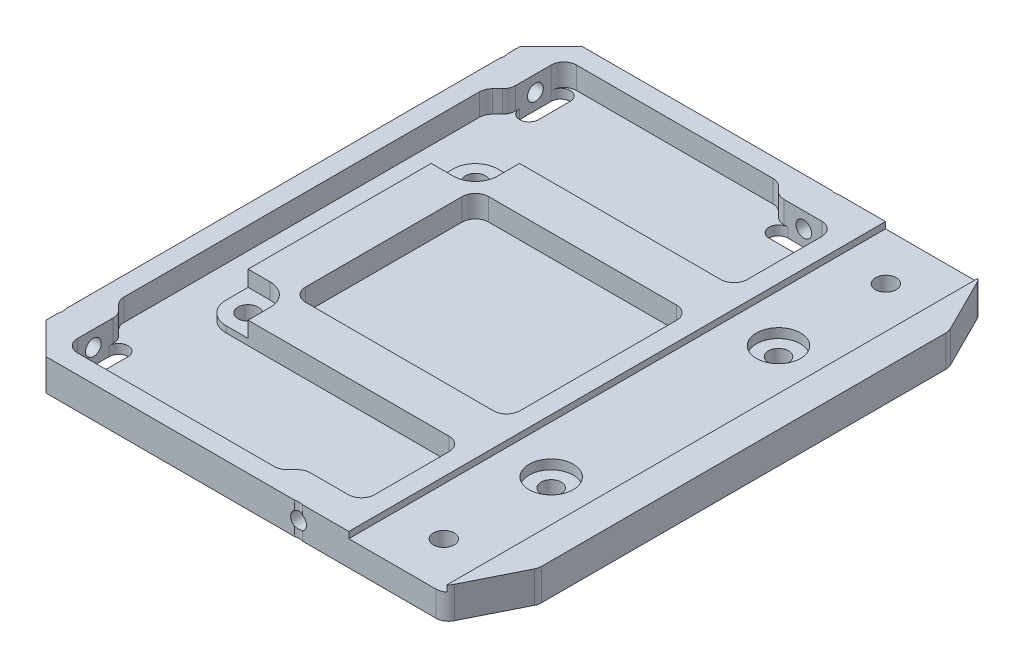
from build123d import *

# Parameters (mm, degrees)
SKETCH_1_R          = 1.6
SKETCH_1_R_2        = 1.65
EXTRUDE_1_DEPTH     = 5
FILLET_1_R          = 2
SKETCH_2_R          = 3.5
CUT_EXTRUDE_1_DEPTH = 2.5
SKETCH_3_W          = 15.1
SKETCH_3_H          = 85
CUT_EXTRUDE_2_DEPTH = 1
SKETCH_4_R          = 1.25
CUT_EXTRUDE_3_DEPTH = 5
CHAMFER_1_SIZE      = 5
SKETCH_6_R          = 1.25
CUT_EXTRUDE_5_DEPTH = 5
SKETCH_7_R          = 1.25
CUT_EXTRUDE_6_DEPTH = 5
SKETCH_5_R          = 2.1
CUT_EXTRUDE_4_DEPTH = 6
CUT_EXTRUDE_7_DEPTH = 2.5
CUT_EXTRUDE_9_DEPTH = 6.0000001
SKETCH_9_W          = 33.95
SKETCH_9_H          = 29
CUT_EXTRUDE_8_DEPTH = 3.5
FILLET_29_R         = 2.1
FILLET_30_R         = 2


with BuildPart() as part:
    # ｽｹｯﾁ1 → ﾎﾞｽ - 押し出し1 (new body)
    with BuildSketch(Plane(origin=(0, 0, 0), x_dir=(1, 0, 0), z_dir=(0, 1, 0))):
        Polygon((-36.5, -42.5), (31.5, -42.5), (36.5, -32.5), (36.5, 32.5), (31.5, 42.5), (-36.5, 42.5), align=None)
        with Locations((-24, -18)):
            Circle(SKETCH_1_R, mode=Mode.SUBTRACT)
        with Locations((-24, 18)):
            Circle(SKETCH_1_R, mode=Mode.SUBTRACT)
        with Locations((24, 35)):
            Circle(SKETCH_1_R_2, mode=Mode.SUBTRACT)
        with Locations((24, -35)):
            Circle(SKETCH_1_R_2, mode=Mode.SUBTRACT)
        with Locations((24, -18)):
            Circle(SKETCH_1_R, mode=Mode.SUBTRACT)
        with Locations((24, 18)):
            Circle(SKETCH_1_R, mode=Mode.SUBTRACT)
    extrude(amount=EXTRUDE_1_DEPTH)

    # ﾌｨﾚｯﾄ1
    fillet_1_edges = [part.edges().sort_by_distance(p)[0] for p in [
        (31.5, 2.5, -42.5),
        (36.5, 2.5, -32.5),
        (36.5, 2.5, 32.5),
        (31.5, 2.5, 42.5),
    ]]
    fillet(fillet_1_edges, radius=FILLET_1_R)

    # ｽｹｯﾁ2 → ｶｯﾄ - 押し出し1 (cut)
    with BuildSketch(Plane(origin=(0, 5, 0), x_dir=(1, 0, 0), z_dir=(0, 1, 0))):
        with Locations((24, 18)):
            Circle(SKETCH_2_R)
        with Locations((24, -18)):
            Circle(SKETCH_2_R)
    extrude(amount=-CUT_EXTRUDE_1_DEPTH, mode=Mode.SUBTRACT)

    # ｽｹｯﾁ3 → ｶｯﾄ - 押し出し2 (cut)
    with BuildSketch(Plane(origin=(0, 5, 0), x_dir=(1, 0, 0), z_dir=(0, 1, 0))):
        with Locations((24, 0)):
            Rectangle(SKETCH_3_W, SKETCH_3_H)
    extrude(amount=-CUT_EXTRUDE_2_DEPTH, mode=Mode.SUBTRACT)

    # ｽｹｯﾁ4 → ｶｯﾄ - 押し出し3 (cut)
    with BuildSketch(Plane.ZY.offset(36.5)):
        with Locations((-35, 2.5)):
            Circle(SKETCH_4_R)
        with Locations((35, 2.5)):
            Circle(SKETCH_4_R)
    extrude(amount=-CUT_EXTRUDE_3_DEPTH, mode=Mode.SUBTRACT)

    # 面取り1
    chamfer_1_edges = [part.edges().sort_by_distance(p)[0] for p in [
        (-36.5, 2.5, 42.5),
        (-36.5, 2.5, -42.5),
    ]]
    chamfer(chamfer_1_edges, length=CHAMFER_1_SIZE)

    # ｽｹｯﾁ6 → ｶｯﾄ - 押し出し5 (cut)
    with BuildSketch(Plane.XY.offset(42.5)):
        with Locations((8.5, 2.5)):
            Circle(SKETCH_6_R)
    extrude(amount=-CUT_EXTRUDE_5_DEPTH, mode=Mode.SUBTRACT)

    # ｽｹｯﾁ7 → ｶｯﾄ - 押し出し6 (cut)
    with BuildSketch(Plane(origin=(0, 0, -42.5), x_dir=(-1, 0, 0), z_dir=(0, 0, -1))):
        with Locations((-8.5, 2.5)):
            Circle(SKETCH_7_R)
    extrude(amount=-CUT_EXTRUDE_6_DEPTH, mode=Mode.SUBTRACT)

    # ｽｹｯﾁ5 → ｶｯﾄ - 押し出し4 (cut, through all)
    with BuildSketch(Plane(origin=(0, 5, 0), x_dir=(1, 0, 0), z_dir=(0, 1, 0))):
        with Locations((-38.5, 35)):
            Circle(SKETCH_5_R)
        with Locations((-38.5, -35)):
            Circle(SKETCH_5_R)
        with Locations((8.5, -44.5)):
            Circle(SKETCH_5_R)
        with Locations((8.5, 44.5)):
            Circle(SKETCH_5_R)
    extrude(amount=-CUT_EXTRUDE_4_DEPTH, mode=Mode.SUBTRACT)

    # ｽｹｯﾁ8 → ｶｯﾄ - 押し出し7 (cut)
    with BuildSketch(Plane(origin=(0, 5, 0), x_dir=(1, 0, 0), z_dir=(0, 1, 0))):
        with BuildLine():
            Line((-20.5, 18), (-20.5, 21.5))
            Line((-20.5, 21.5), (-24, 21.5))
            ThreePointArc((-24, 21.5), (-26.474873734, 20.474873734), (-27.5, 18))
            Line((-27.5, 18), (-27.5, 14.5))
            Line((-27.5, 14.5), (-24, 14.5))
            ThreePointArc((-24, 14.5), (-21.525126266, 15.525126266), (-20.5, 18))
        make_face()
        with BuildLine():
            Line((-27.5, -18), (-27.5, -14.5))
            Line((-27.5, -14.5), (-24, -14.5))
            ThreePointArc((-24, -14.5), (-21.525126266, -15.525126266), (-20.5, -18))
            Line((-20.5, -18), (-20.5, -21.5))
            Line((-20.5, -21.5), (-24, -21.5))
            ThreePointArc((-24, -21.5), (-26.474873734, -20.474873734), (-27.5, -18))
        make_face()
    extrude(amount=-CUT_EXTRUDE_7_DEPTH, mode=Mode.SUBTRACT)

    # ｽｹｯﾁ10 → ｶｯﾄ - 押し出し9 (cut, through all)
    with BuildSketch(Plane(origin=(0, 5, 0), x_dir=(1, 0, 0), z_dir=(0, 1, 0))):
        with BuildLine():
            Line((-31.5, 32.5), (-31.5, 37.5))
            ThreePointArc((-31.5, 37.5), (-30, 39), (-28.5, 37.5))
            Line((-28.5, 37.5), (-28.5, 32.5))
            ThreePointArc((-28.5, 32.5), (-30, 31), (-31.5, 32.5))
        make_face()
        with BuildLine():
            Line((6, 37.5), (11, 37.5))
            ThreePointArc((11, 37.5), (12.5, 36), (11, 34.5))
            Line((11, 34.5), (6, 34.5))
            ThreePointArc((6, 34.5), (4.5, 36), (6, 37.5))
        make_face()
        with BuildLine():
            Line((6, -37.5), (11, -37.5))
            ThreePointArc((11, -37.5), (12.5, -36), (11, -34.5))
            Line((11, -34.5), (6, -34.5))
            ThreePointArc((6, -34.5), (4.5, -36), (6, -37.5))
        make_face()
        with BuildLine():
            Line((-31.5, -32.5), (-31.5, -37.5))
            ThreePointArc((-31.5, -37.5), (-30, -39), (-28.5, -37.5))
            Line((-28.5, -37.5), (-28.5, -32.5))
            ThreePointArc((-28.5, -32.5), (-30, -31), (-31.5, -32.5))
        make_face()
    extrude(amount=-CUT_EXTRUDE_9_DEPTH, mode=Mode.SUBTRACT)

    # ｽｹｯﾁ9 → ｶｯﾄ - 押し出し8 (cut)
    with BuildSketch(Plane(origin=(0, 5, 0), x_dir=(1, 0, 0), z_dir=(0, 1, 0))):
        with Locations((-3.525, 0)):
            Rectangle(SKETCH_9_W, SKETCH_9_H)
        with BuildLine():
            Line((-24, 21.5), (13.45, 21.5))
            Line((13.45, 21.5), (13.45, 34.5))
            Line((13.45, 34.5), (13.45, 37.5))
            Line((13.45, 37.5), (11, 37.5))
            Line((11, 37.5), (6, 37.5))
            Line((6, 37.5), (4.5, 37.5))
            Line((4.5, 37.5), (2.5, 39.5))
            Line((2.5, 39.5), (-31.5, 39.5))
            Line((-31.5, 39.5), (-31.5, 37.5))
            Line((-31.5, 37.5), (-31.5, 32.5))
            Line((-31.5, 32.5), (-31.5, 31))
            Line((-31.5, 31), (-33.5, 29))
            Line((-33.5, 29), (-33.5, -29))
            Line((-33.5, -29), (-31.5, -31))
            Line((-31.5, -31), (-31.5, -32.5))
            Line((-31.5, -32.5), (-31.5, -37.5))
            Line((-31.5, -37.5), (-31.5, -39.5))
            Line((-31.5, -39.5), (2.5, -39.5))
            Line((2.5, -39.5), (4.5, -37.5))
            Line((4.5, -37.5), (6, -37.5))
            Line((6, -37.5), (11, -37.5))
            Line((11, -37.5), (13.45, -37.5))
            Line((13.45, -37.5), (13.45, -34.5))
            Line((13.45, -34.5), (13.45, -21.5))
            Line((13.45, -21.5), (-24, -21.5))
            ThreePointArc((-24, -21.5), (-26.474873734, -20.474873734), (-27.5, -18))
            Line((-27.5, -18), (-27.5, 18))
            ThreePointArc((-27.5, 18), (-26.474873734, 20.474873734), (-24, 21.5))
        make_face()
    extrude(amount=-CUT_EXTRUDE_8_DEPTH, mode=Mode.SUBTRACT)

    # ﾌｨﾚｯﾄ29
    fillet_29_edges = [part.edges().sort_by_distance(p)[0] for p in [
        (13.45, 3.25, -21.5),
        (4.5, 3.25, -37.5),
        (13.45, 3.25, 37.5),
        (-31.5, 3.25, -31),
        (13.45, 3.25, 21.5),
        (4.5, 3.25, 37.5),
        (2.5, 3.25, 39.5),
        (-31.5, 3.25, 31),
        (-33.5, 3.25, 29),
        (-33.5, 3.25, -29),
        (2.5, 3.25, -39.5),
        (13.45, 3.25, -37.5),
        (-20.5, 3.25, 14.5),
        (-20.5, 3.25, -14.5),
        (13.45, 3.25, -14.5),
        (13.45, 3.25, 14.5),
    ]]
    fillet(fillet_29_edges, radius=FILLET_29_R)

    # ﾌｨﾚｯﾄ30
    fillet_30_edges = [part.edges().sort_by_distance(p)[0] for p in [
        (-31.5, 3.25, 39.5),
        (-31.5, 3.25, -39.5),
    ]]
    fillet(fillet_30_edges, radius=FILLET_30_R)


solid = part.part
